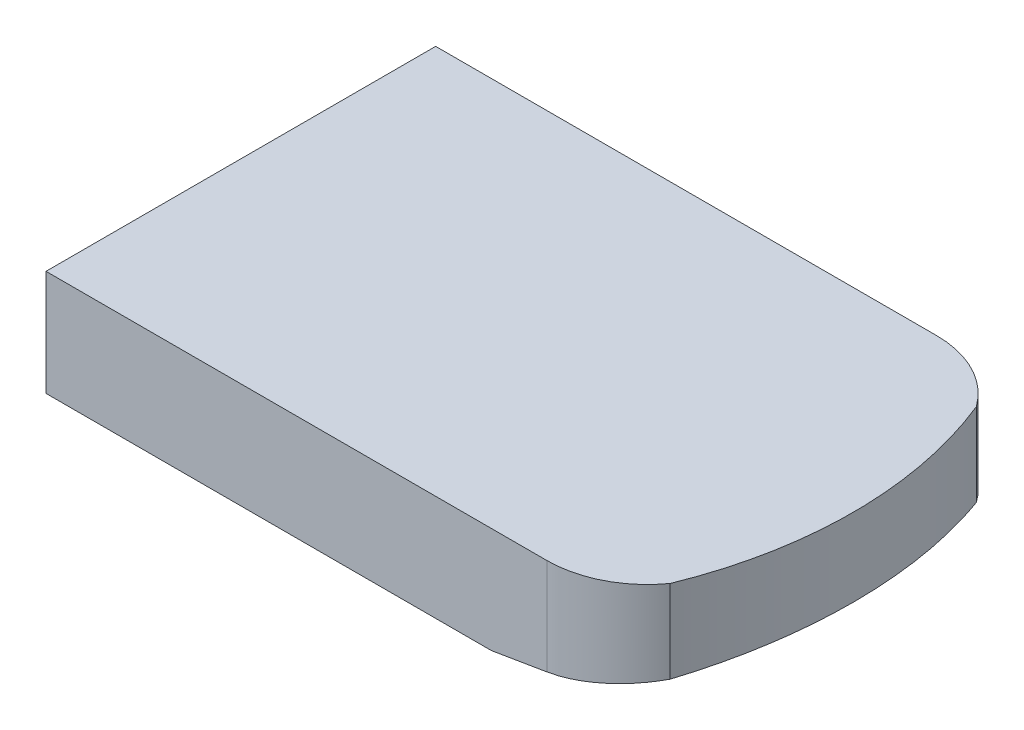
from build123d import *

# Parameters (mm, degrees)
BOSS_EXTRUDE1_DEPTH = 19
CUT_EXTRUDE1_DEPTH  = 70


with BuildPart() as part:
    # Sketch1 → Boss-Extrude1 (new body)
    with BuildSketch(Plane(origin=(0, 0, 0), x_dir=(1, 0, 0), z_dir=(0, 1, 0))):
        with BuildLine():
            Line((0, 0), (90, 0))
            ThreePointArc((90, 0), (98.219216869, 1.986116209), (104.624620421, 7.506169549))
            ThreePointArc((104.624620421, 7.506169549), (110, 35), (104.624620421, 62.493830451))
            ThreePointArc((104.624620421, 62.493830451), (98.219216869, 68.013883791), (90, 70))
            Line((90, 70), (0, 70))
            Line((0, 70), (0, 0))
        make_face()
    extrude(amount=BOSS_EXTRUDE1_DEPTH)

    # Sketch3 → Cut-Extrude1 (cut)
    with BuildSketch(Plane.XY):
        Polygon((110, 5), (80, 0), (110, 0), align=None)
    extrude(amount=-CUT_EXTRUDE1_DEPTH, mode=Mode.SUBTRACT)


solid = part.part
